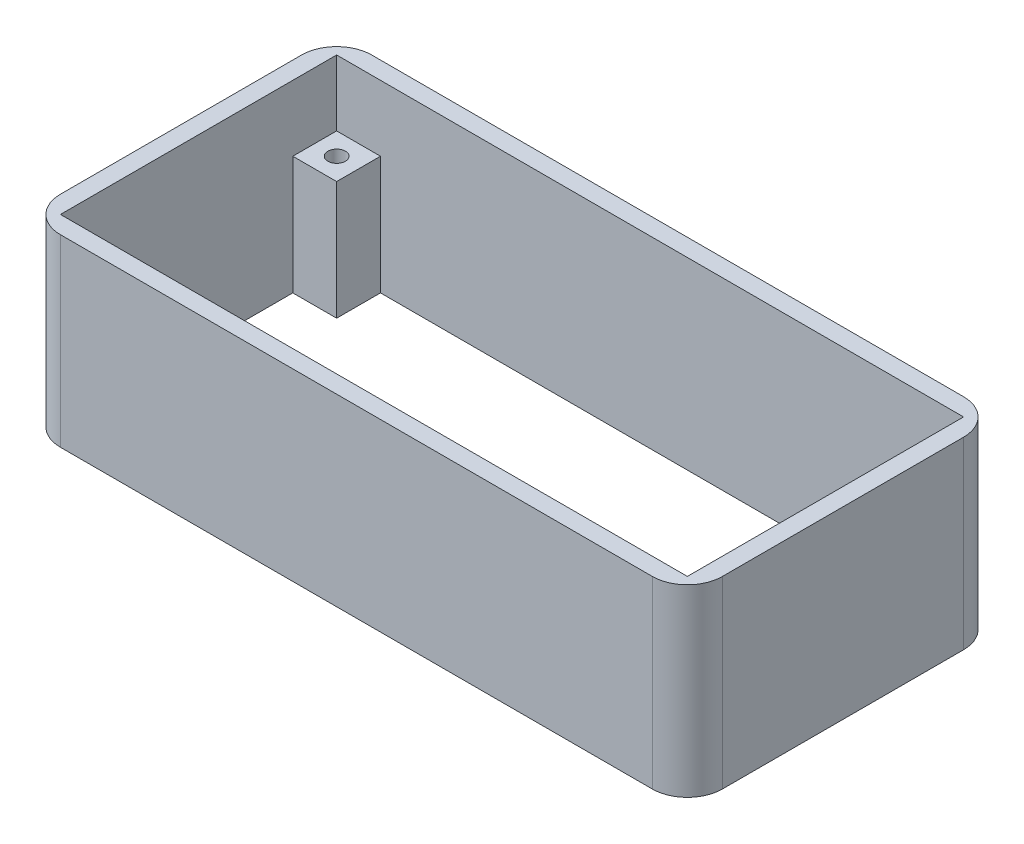
from build123d import *

# Parameters (mm, degrees)
SKETCH1_W             = 10
SKETCH1_H             = 10
SKETCH1_R             = 2
BOSS_EXTRUDE5_DEPTH   = 27
BOSS_EXTRUDE5_2_DEPTH = 27
BOSS_EXTRUDE5_3_DEPTH = 27
BOSS_EXTRUDE5_4_DEPTH = 27
BOSS_EXTRUDE6_DEPTH   = 42


with BuildPart() as part:
    # Sketch1 → Boss-Extrude5 (new body)
    with BuildSketch(Plane(origin=(0, 0, 0), x_dir=(1, 0, 0), z_dir=(0, 1, 0))):
        with Locations((-89.708361573, 21.452000773)):
            Rectangle(SKETCH1_W, SKETCH1_H)
        with Locations((-89.708361573, 21.452000773)):
            Circle(SKETCH1_R, mode=Mode.SUBTRACT)
    extrude(amount=BOSS_EXTRUDE5_DEPTH)



with BuildPart() as body_2:
    # Sketch1 → Boss-Extrude5 2 (new body)
    with BuildSketch(Plane(origin=(0, 0, 0), x_dir=(1, 0, 0), z_dir=(0, 1, 0))):
        with Locations((43.291638427, 21.452000773)):
            Rectangle(SKETCH1_W, SKETCH1_H)
        with Locations((43.291638427, 21.452000773)):
            Circle(SKETCH1_R, mode=Mode.SUBTRACT)
    extrude(amount=BOSS_EXTRUDE5_2_DEPTH)


with BuildPart() as body_3:
    # Sketch1 → Boss-Extrude5 3 (new body)
    with BuildSketch(Plane(origin=(0, 0, 0), x_dir=(1, 0, 0), z_dir=(0, 1, 0))):
        with Locations((-89.708361573, -31.547999227)):
            Rectangle(SKETCH1_W, SKETCH1_H)
        with Locations((-89.708361573, -31.547999227)):
            Circle(SKETCH1_R, mode=Mode.SUBTRACT)
    extrude(amount=BOSS_EXTRUDE5_3_DEPTH)


with BuildPart() as body_4:
    # Sketch1 → Boss-Extrude5 4 (new body)
    with BuildSketch(Plane(origin=(0, 0, 0), x_dir=(1, 0, 0), z_dir=(0, 1, 0))):
        with Locations((43.291638427, -31.547999227)):
            Rectangle(SKETCH1_W, SKETCH1_H)
        with Locations((43.291638427, -31.547999227)):
            Circle(SKETCH1_R, mode=Mode.SUBTRACT)
    extrude(amount=BOSS_EXTRUDE5_4_DEPTH)


with BuildPart() as part_1:
    add(part.part)

    add(body_2.part)  # Boss-Extrude6 merges body 2

    add(body_3.part)  # Boss-Extrude6 merges body 3

    add(body_4.part)  # Boss-Extrude6 merges body 4
    # Sketch1_7 → Boss-Extrude6 (add)
    with BuildSketch(Plane(origin=(0, 0, 0), x_dir=(1, 0, 0), z_dir=(0, 1, 0))):
        with BuildLine():
            Line((44.291638427, 30.452000773), (-90.708361573, 30.452000773))
            ThreePointArc((-90.708361573, 30.452000773), (-96.365215823, 28.108855023), (-98.708361573, 22.452000773))
            Line((-98.708361573, 22.452000773), (-98.708361573, -32.547999227))
            ThreePointArc((-98.708361573, -32.547999227), (-96.365215823, -38.204853476), (-90.708361573, -40.547999227))
            Line((-90.708361573, -40.547999227), (44.291638427, -40.547999227))
            ThreePointArc((44.291638427, -40.547999227), (49.948492676, -38.204853476), (52.291638427, -32.547999227))
            Line((52.291638427, -32.547999227), (52.291638427, 22.452000773))
            ThreePointArc((52.291638427, 22.452000773), (49.948492676, 28.108855023), (44.291638427, 30.452000773))
        make_face()
        Polygon((-94.708361573, 16.452000773), (-94.708361573, 26.452000773), (-84.708361573, 26.452000773), (38.291638427, 26.452000773), (48.291638427, 26.452000773), (48.291638427, 16.452000773), (48.291638427, -26.547999227), (48.291638427, -36.547999227), (38.291638427, -36.547999227), (-84.708361573, -36.547999227), (-94.708361573, -36.547999227), (-94.708361573, -26.547999227), align=None, mode=Mode.SUBTRACT)
    extrude(amount=BOSS_EXTRUDE6_DEPTH)


solid = part_1.part
